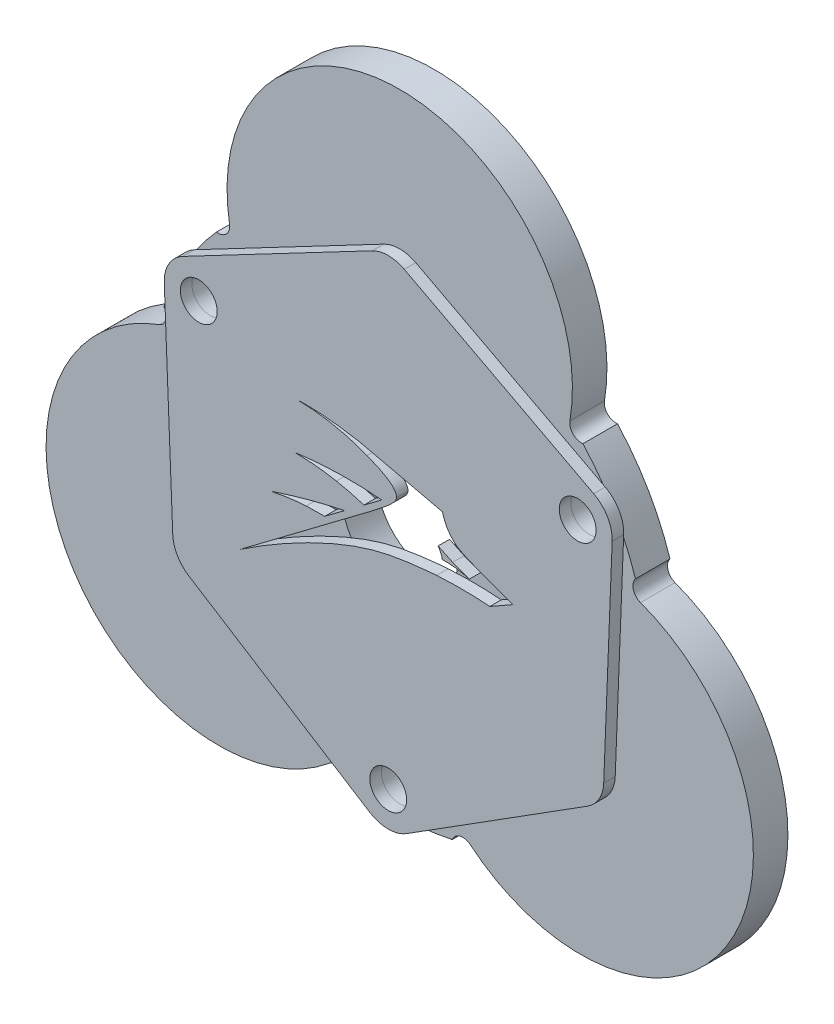
from build123d import *

# Parameters (mm, degrees)
SKETCH_1_R               = 21.5
SKETCH_1_R_2             = 5
SKETCH_1_R_3             = 2
SKETCH_1_R_4             = 1.6
EXTRUDE_1_DEPTH          = 3
EXTRUDE_2_DEPTH          = 3
SKETCH_3_R               = 1
CUT_EXTRUDE_1_DEPTH      = 4
PATTERN_CIRCULAR_1_COUNT = 3
SKETCH_6_R               = 1.6
EXTRUDE_3_DEPTH          = 1
CUT_EXTRUDE_2_DEPTH      = 5


with BuildPart() as part:
    # 草图1 → 凸台-拉伸1 (new body)
    with BuildSketch(Plane.XY):
        Circle(SKETCH_1_R)
        Circle(SKETCH_1_R_2, mode=Mode.SUBTRACT)
        with Locations((0, 18.15)):
            Circle(SKETCH_1_R_3, mode=Mode.SUBTRACT)
        with Locations((16.454482672, 9.5)):
            Circle(SKETCH_1_R_4, mode=Mode.SUBTRACT)
        with Locations((15.718361079, -9.075)):
            Circle(SKETCH_1_R_3, mode=Mode.SUBTRACT)
        with Locations((0, -19)):
            Circle(SKETCH_1_R_4, mode=Mode.SUBTRACT)
        with Locations((-15.718361079, -9.075)):
            Circle(SKETCH_1_R_3, mode=Mode.SUBTRACT)
        with Locations((-16.454482672, 9.5)):
            Circle(SKETCH_1_R_4, mode=Mode.SUBTRACT)
    extrude(amount=EXTRUDE_1_DEPTH)

    # 草图2 → 凸台-拉伸2 (add)
    with BuildSketch(Plane.XY.offset(3)):
        with BuildLine():
            ThreePointArc((14.432151422, 14.06184573), (0, 33.15), (-14.432151422, 14.06184573))
            ThreePointArc((-14.432151422, 14.06184573), (0, 20.15), (14.432151422, 14.06184573))
        make_face()
    extrude_2 = extrude(amount=-EXTRUDE_2_DEPTH)

    # 草图3 → 切除-拉伸1 (cut, through all)
    with BuildSketch(Plane.XY.offset(3)):
        with Locations((-15.769090313, 15.441533517)):
            Circle(SKETCH_3_R)
        with Locations((15.769090313, 15.441533517)):
            Circle(SKETCH_3_R)
    cut_extrude_1 = extrude(amount=-CUT_EXTRUDE_1_DEPTH, mode=Mode.SUBTRACT)

    # 阵列(圆周)1: 凸台-拉伸2, 切除-拉伸1 ×3 about axis
    pattern_circular_1_axis = Axis((0, 0, 0), (0, 0, 1))
    for i in range(1, PATTERN_CIRCULAR_1_COUNT):
        add(extrude_2.rotate(pattern_circular_1_axis, i * 360 / PATTERN_CIRCULAR_1_COUNT))
        add(cut_extrude_1.rotate(pattern_circular_1_axis, i * 360 / PATTERN_CIRCULAR_1_COUNT), mode=Mode.SUBTRACT)


with BuildPart() as body_2:
    # 草图6 → 凸台-拉伸3 (new body)
    with BuildSketch(Plane.XY.offset(3)):
        with BuildLine():
            Line((-17.85042596, 12.155436374), (-1.395943288, 20.805436374))
            ThreePointArc((-1.395943288, 20.805436374), (0, 21.15), (1.395943288, 20.805436374))
            Line((1.395943288, 20.805436374), (17.85042596, 12.155436374))
            ThreePointArc((17.85042596, 12.155436374), (19.052558883, 11), (19.452129674, 9.381204162))
            Line((19.452129674, 9.381204162), (18.716008081, -9.193795838))
            ThreePointArc((18.716008081, -9.193795838), (18.31643729, -10.575), (17.320064793, -11.611640536))
            Line((17.320064793, -11.611640536), (1.601703714, -21.536640536))
            ThreePointArc((1.601703714, -21.536640536), (0, -22), (-1.601703714, -21.536640536))
            Line((-1.601703714, -21.536640536), (-17.320064793, -11.611640536))
            ThreePointArc((-17.320064793, -11.611640536), (-18.31643729, -10.575), (-18.716008081, -9.193795838))
            Line((-18.716008081, -9.193795838), (-19.452129674, 9.381204162))
            ThreePointArc((-19.452129674, 9.381204162), (-19.052558883, 11), (-17.85042596, 12.155436374))
        make_face()
        with Locations((16.454482672, 9.5)):
            Circle(SKETCH_6_R, mode=Mode.SUBTRACT)
        with Locations((0, -19)):
            Circle(SKETCH_6_R, mode=Mode.SUBTRACT)
        with Locations((-16.454482672, 9.5)):
            Circle(SKETCH_6_R, mode=Mode.SUBTRACT)
    extrude(amount=EXTRUDE_3_DEPTH)

    # 草图7 → 切除-拉伸2 (cut, through all)
    with BuildSketch(Plane.XY.offset(4)):
        with BuildLine():
            Line((-0.567203304, 2.4762914), (-2.108100929, 1.32056635))
            add(Edge.make_bspline(
                [(-2.108100929, 1.32056635), (-2.814082647, 1.549273513), (-3.613572334, 1.764356857), (-4.498562988, 1.932761282)],
                knots=[1, 1, 1, 1, 2, 2, 2, 2], degree=3))
            add(Edge.make_bspline(
                [(-4.498562988, 1.932761282), (-5.839892029, 2.188001174), (-7.054117051, 2.27445059), (-8.082346073, 2.280055492)],
                knots=[2, 2, 2, 2, 3, 3, 3, 3], degree=3))
            add(Edge.make_bspline(
                [(-8.082346073, 2.280055492), (-6.935522856, 2.442609562), (-5.642380005, 2.564041953), (-4.225257296, 2.596503677)],
                knots=[3, 3, 3, 3, 4, 4, 4, 4], degree=3))
            add(Edge.make_bspline(
                [(-4.225257296, 2.596503677), (-2.891469375, 2.627056588), (-1.665167123, 2.573821935), (-0.567203304, 2.4762914)],
                knots=[4, 4, 4, 4, 5, 5, 5, 5], degree=3))
        make_face()
        with BuildLine():
            Line((-3.796987506, 0.060981419), (-5.515924172, -1.228274699))
            add(Edge.make_bspline(
                [(-5.515924172, -1.228274699), (-6.022798422, -1.217846532), (-6.561218119, -1.225717701), (-7.127503852, -1.259058765)],
                knots=[1, 1, 1, 1, 2, 2, 2, 2], degree=3))
            add(Edge.make_bspline(
                [(-7.127503852, -1.259058765), (-8.253912787, -1.325378671), (-9.272358253, -1.479625476), (-10.164813769, -1.669348545)],
                knots=[2, 2, 2, 2, 3, 3, 3, 3], degree=3))
            add(Edge.make_bspline(
                [(-10.164813769, -1.669348545), (-9.217958295, -1.348770558), (-8.211275498, -1.037238577), (-7.147025687, -0.744982978)],
                knots=[3, 3, 3, 3, 4, 4, 4, 4], degree=3))
            add(Edge.make_bspline(
                [(-7.147025687, -0.744982978), (-5.980248114, -0.424571804), (-4.860466404, -0.159242135), (-3.796987506, 0.060981419)],
                knots=[4, 4, 4, 4, 5, 5, 5, 5], degree=3))
        make_face()
        with BuildLine():
            add(Edge.make_bspline(
                [(10.834847178, 0.304994749), (9.896142528, 0.630579511), (8.843130942, 1.011950556), (7.696077625, 1.454477392)],
                knots=[15, 15, 15, 15, 16, 16, 16, 16], degree=3))
            add(Edge.make_bspline(
                [(7.696077625, 1.454477392), (6.539171022, 1.900804414), (5.948543528, 2.153972486), (5.438050702, 2.762439536)],
                knots=[0, 0, 0, 0, 1, 1, 1, 1], degree=3))
            add(Edge.make_bspline(
                [(5.438050702, 2.762439536), (5.004711935, 3.278952384), (4.81155666, 3.834022049), (4.717162107, 4.22033995)],
                knots=[1, 1, 1, 1, 2, 2, 2, 2], degree=3))
            add(Edge.make_bspline(
                [(4.717162107, 4.22033995), (3.846269087, 4.420562689), (2.538112156, 4.722953087), (0.941523343, 5.098550349)],
                knots=[2, 2, 2, 2, 3, 3, 3, 3], degree=3))
            add(Edge.make_bspline(
                [(0.941523343, 5.098550349), (-1.531144237, 5.680247039), (-1.817947994, 5.760558119), (-2.520350193, 5.892439995)],
                knots=[3, 3, 3, 3, 4, 4, 4, 4], degree=3))
            add(Edge.make_bspline(
                [(-2.520350193, 5.892439995), (-5.630291258, 6.476360198), (-7.790391734, 6.36316318), (-7.791244387, 6.347947737)],
                knots=[4, 4, 4, 4, 5, 5, 5, 5], degree=3))
            add(Edge.make_bspline(
                [(-7.791244387, 6.347947737), (-7.792218323, 6.330611687), (-4.989419725, 6.434955081), (-1.830576077, 5.176637916)],
                knots=[5, 5, 5, 5, 6, 6, 6, 6], degree=3))
            add(Edge.make_bspline(
                [(-1.830576077, 5.176637916), (-0.84377372, 4.783550244), (0.726584992, 4.140841096), (0.720274626, 3.302543672)],
                knots=[6, 6, 6, 6, 7, 7, 7, 7], degree=3))
            add(Edge.make_bspline(
                [(0.720274626, 3.302543672), (0.717099229, 2.880583411), (-0.006641343, 2.318280898), (-1.454118811, 1.193675873)],
                knots=[7, 7, 7, 7, 8, 8, 8, 8], degree=3))
            add(Edge.make_bspline(
                [(-1.454118811, 1.193675873), (-1.788674804, 0.933741707), (-1.959808114, 0.814425434), (-2.830517373, 0.161333768)],
                knots=[8, 8, 8, 8, 9, 9, 9, 9], degree=3))
            add(Edge.make_bspline(
                [(-2.830517373, 0.161333768), (-2.851668309, 0.145464134), (-4.548498962, -1.127208472), (-4.549454522, -1.127925141), (-5.351370865, -1.729401908), (-7.436176948, -3.298522068), (-12.834384711, -7.369391887)],
                knots=[9, 9, 9, 9, 10, 10, 10, 11, 11, 11, 11], degree=3))
            add(Edge.make_bspline(
                [(-12.834384711, -7.369391887), (-12.288352432, -6.995180185), (-5.604939537, -2.470386649), (-0.008541436, -1.356667648), (2.041191948, -0.948757783), (4.208168775, -0.810054683), (4.208176125, -0.810054683)],
                knots=[11, 11, 11, 11, 12, 12, 12, 13, 13, 13, 13], degree=3))
            add(Edge.make_bspline(
                [(4.208176125, -0.810054683), (6.003429381, -0.695148684), (7.568837561, -0.743599213), (8.822200519, -0.840544374)],
                knots=[13, 13, 13, 13, 14, 14, 14, 14], degree=3))
            add(Edge.make_bspline(
                [(8.822200519, -0.840544374), (9.493080289, -0.458699224), (10.163967409, -0.0768504), (10.834847178, 0.304994749)],
                knots=[14, 14, 14, 14, 15, 15, 15, 15], degree=3))
        make_face()
        with BuildLine():
            add(Edge.make_bspline(
                [(5.897222646, 0.566399007), (5.445241286, 0.625461756), (5.038314544, 0.63697992), (4.69292398, 0.62661394)],
                knots=[5, 5, 5, 5, 6, 6, 6, 6], degree=3))
            add(Edge.make_bspline(
                [(4.69292398, 0.62661394), (4.673755829, 0.7423046), (4.638765822, 0.888060462), (4.572494113, 1.048118473)],
                knots=[0, 0, 0, 0, 1, 1, 1, 1], degree=3))
            add(Edge.make_bspline(
                [(4.572494113, 1.048118473), (4.497912714, 1.228243228), (4.407625229, 1.368728813), (4.33163438, 1.469623006)],
                knots=[1, 1, 1, 1, 2, 2, 2, 2], degree=3))
            add(Edge.make_bspline(
                [(4.33163438, 1.469623006), (4.715934581, 1.267020557), (5.137648602, 1.063307271), (5.596147979, 0.867473673)],
                knots=[2, 2, 2, 2, 3, 3, 3, 3], degree=3))
            add(Edge.make_bspline(
                [(5.596147979, 0.867473673), (6.104860157, 0.650192364), (6.589859764, 0.472083471), (7.041888903, 0.325386751)],
                knots=[3, 3, 3, 3, 4, 4, 4, 4], degree=3))
            add(Edge.make_bspline(
                [(7.041888903, 0.325386751), (6.718599321, 0.420134126), (6.334181512, 0.509300666), (5.897222646, 0.566399007)],
                knots=[4, 4, 4, 4, 5, 5, 5, 5], degree=3))
        make_face(mode=Mode.SUBTRACT)
    extrude(amount=-CUT_EXTRUDE_2_DEPTH, mode=Mode.SUBTRACT)


solid = Compound([part.part, body_2.part])
